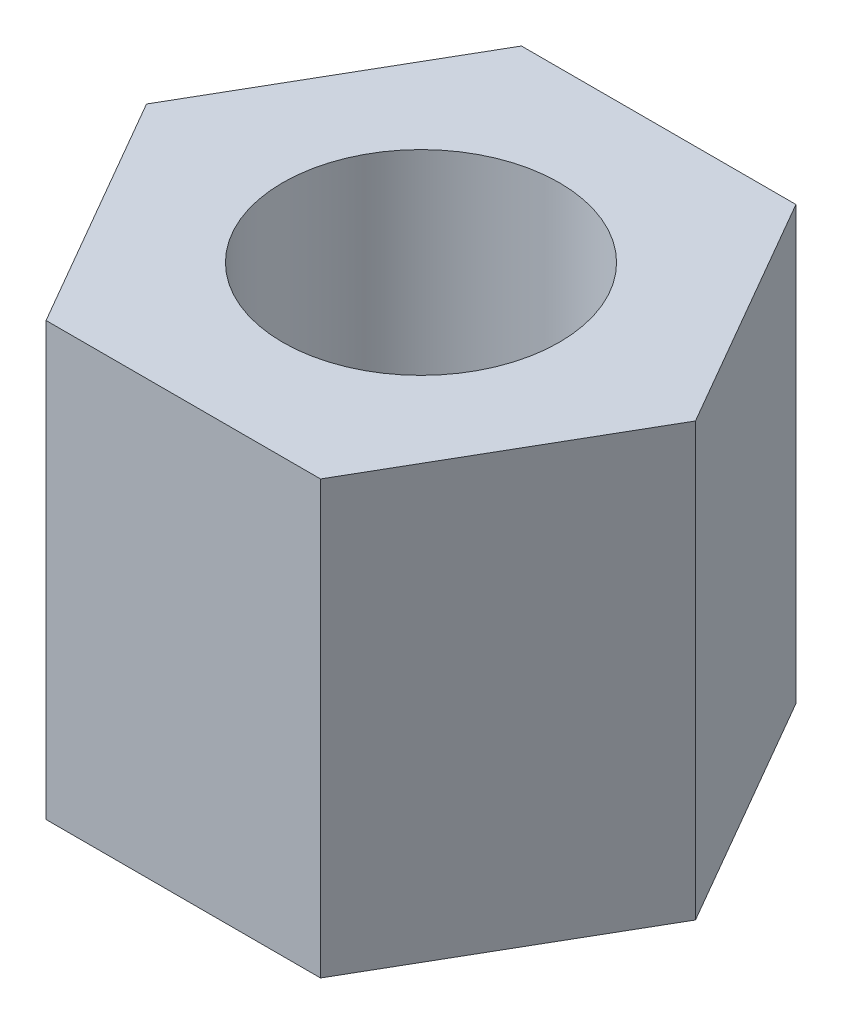
from build123d import *

# Parameters (mm, degrees)
EXTRUDE_1_DEPTH     = 5
SKETCH_2_R          = 1.6
CUT_EXTRUDE_1_DEPTH = 6


with BuildPart() as part:
    # 草图1 → 凸台-拉伸1 (new body)
    with BuildSketch(Plane(origin=(0, 0, 0), x_dir=(1, 0, 0), z_dir=(0, 1, 0))):
        Polygon((3.175426481, 0), (1.58771324, 2.75), (-1.58771324, 2.75), (-3.175426481, 0), (-1.58771324, -2.75), (1.58771324, -2.75), align=None)
    extrude(amount=EXTRUDE_1_DEPTH)

    # 草图2 → 切除-拉伸1 (cut, through all)
    with BuildSketch(Plane(origin=(0, 5, 0), x_dir=(1, 0, 0), z_dir=(0, 1, 0))):
        Circle(SKETCH_2_R)
    extrude(amount=-CUT_EXTRUDE_1_DEPTH, mode=Mode.SUBTRACT)


solid = part.part
